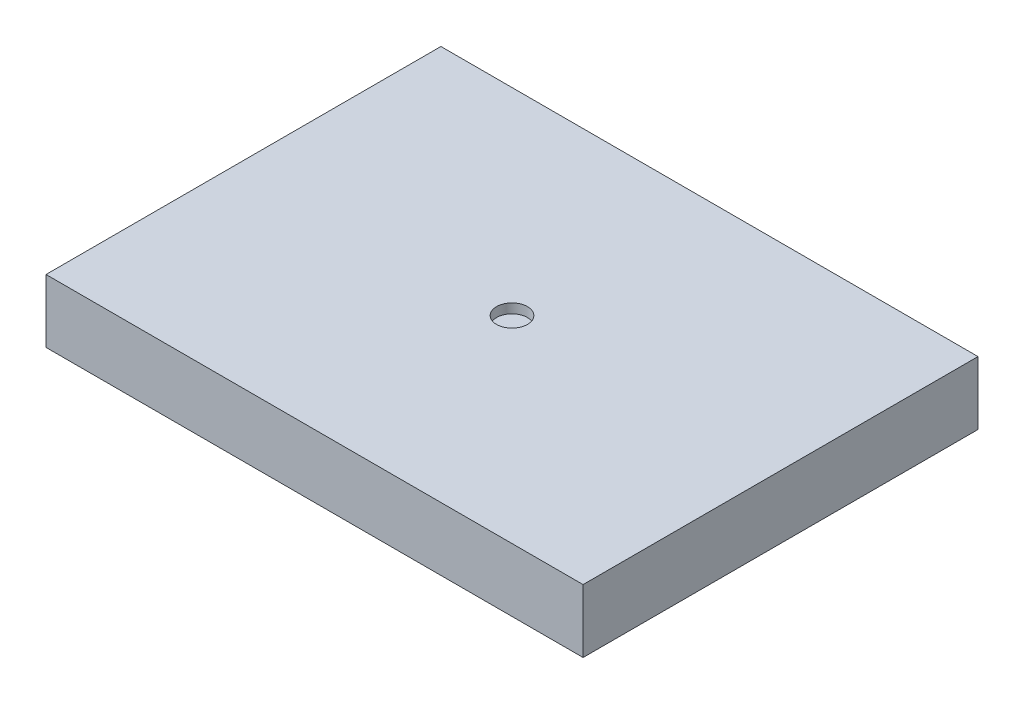
from build123d import *

# Parameters (mm, degrees)
SKETCH1_W           = 43.18
SKETCH1_H           = 31.75
BOSS_EXTRUDE1_DEPTH = 5.08
SKETCH2_R           = 1.242025529
CUT_EXTRUDE1_DEPTH  = 0.762


with BuildPart() as part:
    # Sketch1 → Boss-Extrude1 (new body)
    with BuildSketch(Plane(origin=(0, 0, 0), x_dir=(1, 0, 0), z_dir=(0, 1, 0))):
        Rectangle(SKETCH1_W, SKETCH1_H)
    extrude(amount=BOSS_EXTRUDE1_DEPTH)

    # Sketch2 → Cut-Extrude1 (cut)
    with BuildSketch(Plane(origin=(0, 5.08, 0), x_dir=(1, 0, 0), z_dir=(0, 1, 0))):
        Circle(SKETCH2_R)
    extrude(amount=-CUT_EXTRUDE1_DEPTH, mode=Mode.SUBTRACT)


solid = part.part
